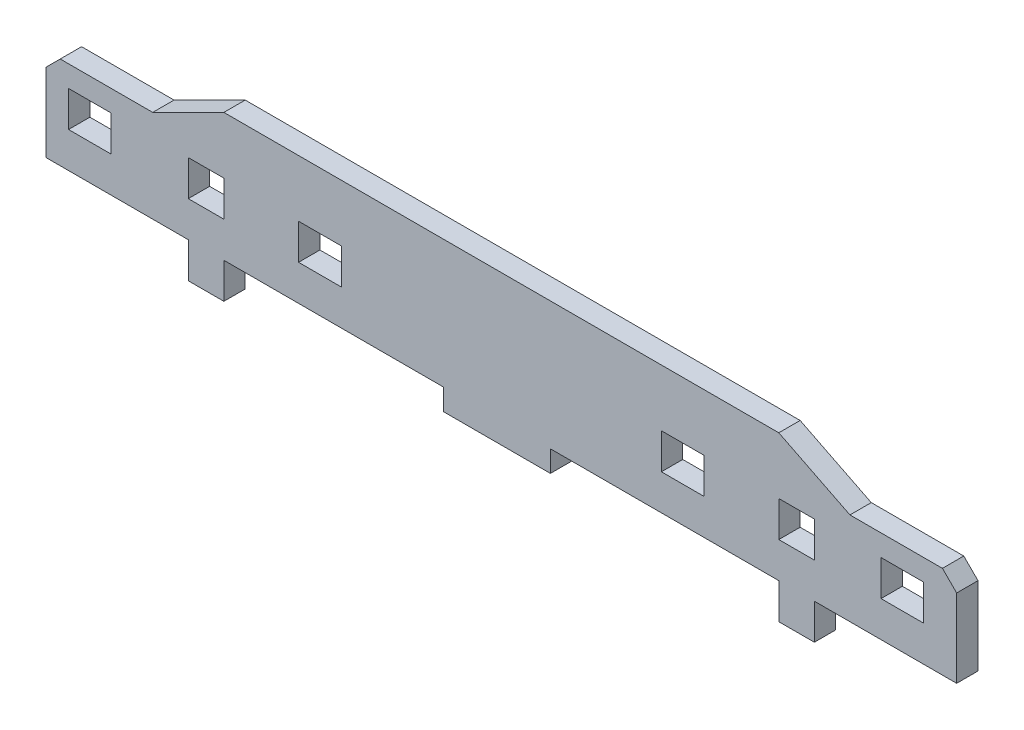
from build123d import *

# Parameters (mm, degrees)
BOSS_EXTRUDE1_DEPTH = 3
SKETCH3_W           = 15
SKETCH3_H           = 13
BOSS_EXTRUDE2_DEPTH = 3
SKETCH2_W           = 6
SKETCH2_H           = 5
SKETCH2_W_2         = 5
CUT_EXTRUDE1_DEPTH  = 3
CHAMFER1_SIZE       = 2
SKETCH4_W           = 15
SKETCH4_H           = 3
BOSS_EXTRUDE3_DEPTH = 3


with BuildPart() as part:
    # Sketch1 → Boss-Extrude1 (new body)
    with BuildSketch(Plane.XY):
        Polygon((0, 0), (-78, 0), (-78, -5), (-83, -5), (-83, 0), (-88, 0), (-88, 13), (-78, 18), (0, 18), (10, 13), (10, 0), (5, 0), (5, -5), (0, -5), align=None)
    extrude(amount=BOSS_EXTRUDE1_DEPTH)

    # Sketch3 → Boss-Extrude2 (add)
    with BuildSketch(Plane.XY.offset(3)):
        with Locations((17.5, 6.5)):
            Rectangle(SKETCH3_W, SKETCH3_H)
        with Locations((-95.5, 6.5)):
            Rectangle(SKETCH3_W, SKETCH3_H)
    extrude(amount=-BOSS_EXTRUDE2_DEPTH)

    # Sketch2 → Cut-Extrude1 (cut)
    with BuildSketch(Plane.XY.offset(3)):
        with Locations((-64.5, 7.5)):
            Rectangle(SKETCH2_W, SKETCH2_H)
        with Locations((-13.5, 7.5)):
            Rectangle(SKETCH2_W, SKETCH2_H)
        with Locations((2.5, 7.5)):
            Rectangle(SKETCH2_W_2, SKETCH2_H)
        with Locations((-80.5, 7.5)):
            Rectangle(SKETCH2_W_2, SKETCH2_H)
        with Locations((17.37, 7.5)):
            Rectangle(SKETCH2_W, SKETCH2_H)
        with Locations((-96.83, 7.5)):
            Rectangle(SKETCH2_W, SKETCH2_H)
    extrude(amount=-CUT_EXTRUDE1_DEPTH, mode=Mode.SUBTRACT)

    # Chamfer1
    chamfer1_edges = [part.edges().sort_by_distance(p)[0] for p in [
        (25, 13, 1.5),
        (-103, 13, 1.5),
    ]]
    chamfer(chamfer1_edges, length=CHAMFER1_SIZE)

    # Sketch4 → Boss-Extrude3 (add)
    with BuildSketch(Plane(origin=(0, 0, 0), x_dir=(-1, 0, 0), z_dir=(0, 0, -1))):
        with Locations((39.602582465, -1.5)):
            Rectangle(SKETCH4_W, SKETCH4_H)
    extrude(amount=-BOSS_EXTRUDE3_DEPTH)


solid = part.part
